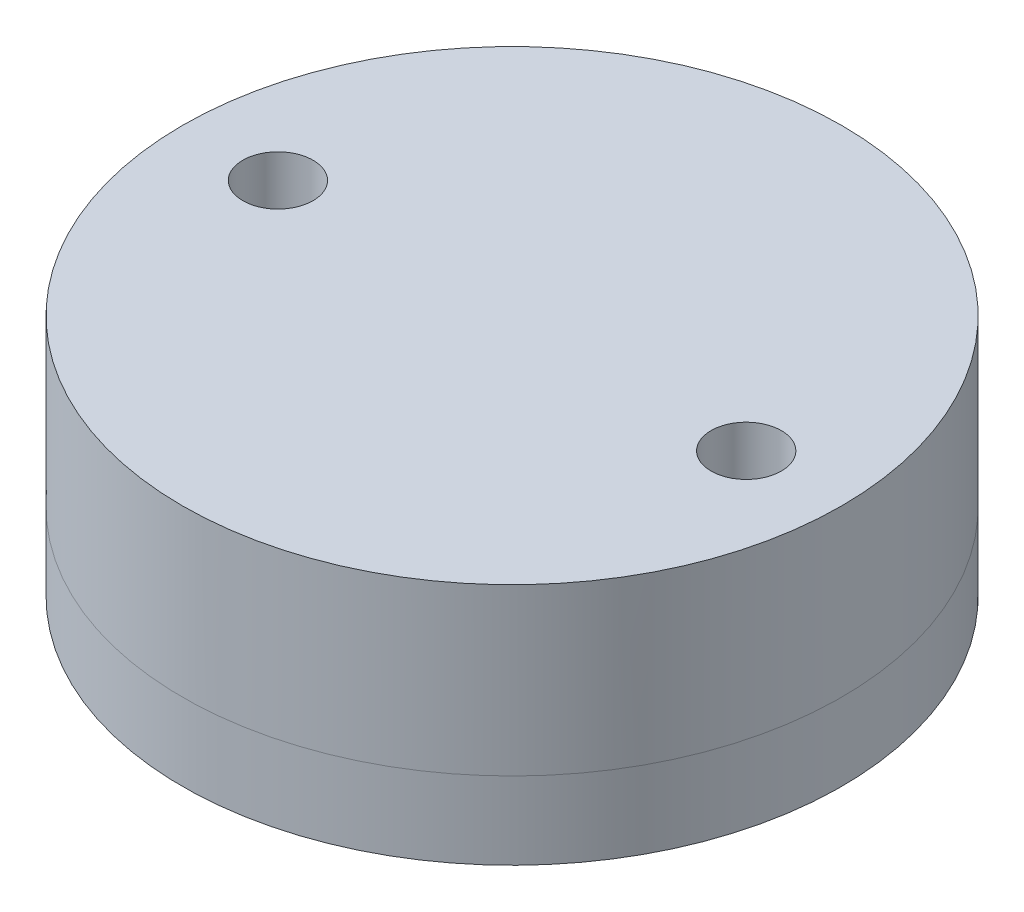
from build123d import *

# Parameters (mm, degrees)
SKETCH2_R          = 1.5
CUT_EXTRUDE1_DEPTH = 25
SKETCH3_R          = 14.075
CUT_EXTRUDE2_DEPTH = 1


with BuildPart() as part:
    # Sketch1 → Revolve1 (revolve)
    with BuildSketch(Plane.XY):
        with BuildLine():
            Line((0, 0), (0, 12.85))
            ThreePointArc((0, 12.85), (-6.425, 6.425), (0, 0))
        make_face()
    revolve(axis=Axis((0, 0, 0), (0, 1, 0)))


with BuildPart() as body_2:
    # Sketch1_3 → Revolve2 (revolve)
    with BuildSketch(Plane.XY):
        with BuildLine():
            Line((14.075, 6.425), (14.075, 14.5))
            Line((14.075, 14.5), (0, 14.5))
            Line((0, 14.5), (0, 13))
            ThreePointArc((0, 13), (4.649227086, 11.074227086), (6.575, 6.425))
            Line((6.575, 6.425), (14.075, 6.425))
        make_face()
    revolve(axis=Axis((0, 0, 0), (0, 1, 0)))


with BuildPart() as body_3:
    # Sketch1_4 → Revolve3 (revolve)
    with BuildSketch(Plane.XY):
        with BuildLine():
            Line((-14.075, 3.122561847), (-7.368821293, 3.122561847))
            ThreePointArc((-7.368821293, 3.122561847), (-6.377682645, 2.744879202), (-6, 3.736017851))
            ThreePointArc((-6, 3.736017851), (-6.429643264, 5.050113641), (-6.575, 6.425))
            Line((-6.575, 6.425), (-14.075, 6.425))
            Line((-14.075, 6.425), (-14.075, 3.122561847))
        make_face()
    revolve(axis=Axis((0, 0, 0), (0, 1, 0)))


with BuildPart() as cut_extrude1_tool:
    # Sketch2 → Cut-Extrude1 (new body)
    with BuildSketch(Plane(origin=(0, 14.5, 0), x_dir=(1, 0, 0), z_dir=(0, 1, 0))):
        with Locations((-10, 0)):
            Circle(SKETCH2_R)
        with Locations((10, 0)):
            Circle(SKETCH2_R)
    extrude(amount=-CUT_EXTRUDE1_DEPTH)


with BuildPart() as body_2_1:
    add(body_2.part)

    # Cut-Extrude1: cut by cut_extrude1_tool
    add(cut_extrude1_tool.part, mode=Mode.SUBTRACT)

    # Sketch3 → Cut-Extrude2 (cut)
    with BuildSketch(Plane(origin=(0, 14.5, 0), x_dir=(1, 0, 0), z_dir=(0, 1, 0))):
        Circle(SKETCH3_R)
    extrude(amount=-CUT_EXTRUDE2_DEPTH, mode=Mode.SUBTRACT)


with BuildPart() as body_3_1:
    add(body_3.part)

    # Cut-Extrude1: cut by cut_extrude1_tool
    add(cut_extrude1_tool.part, mode=Mode.SUBTRACT)


solid = Compound([part.part, body_2_1.part, body_3_1.part])
